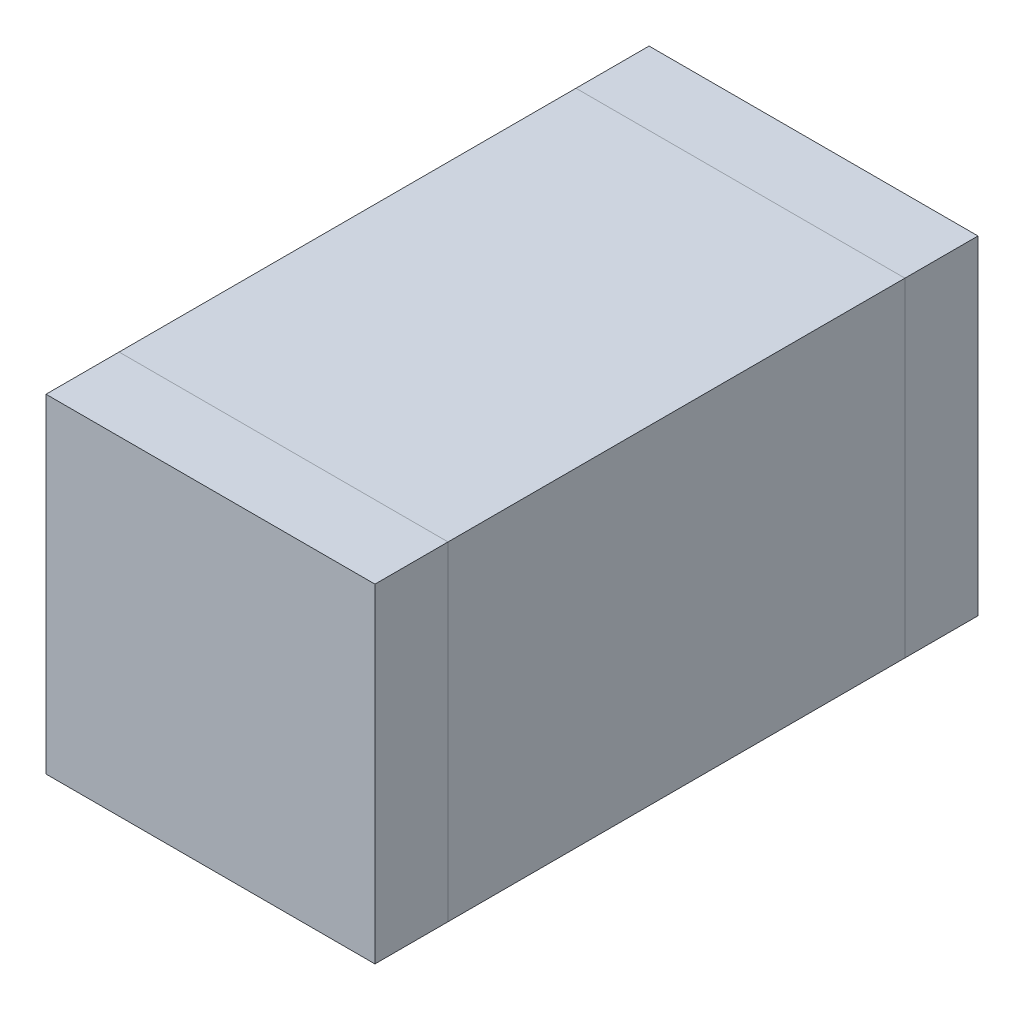
from build123d import *

# Parameters (mm, degrees)
SKETCH1_W  = 1.8
SKETCH1_H  = 2.5
MB_DEPTH   = 1.8
SKETCH2_W  = 1.8
SKETCH2_H  = 1.8
SB_L_DEPTH = 0.4
SKETCH3_W  = 1.8
SKETCH3_H  = 1.8
SB_R_DEPTH = 0.4


with BuildPart() as part:
    # Sketch1 → MB (new body)
    with BuildSketch(Plane(origin=(0, 0, 0), x_dir=(1, 0, 0), z_dir=(0, 1, 0))):
        Rectangle(SKETCH1_W, SKETCH1_H)
    extrude(amount=MB_DEPTH)


with BuildPart() as body_2:
    # Sketch2 → SB L (new body)
    with BuildSketch(Plane.XY.offset(1.25)):
        with Locations((0, 0.9)):
            Rectangle(SKETCH2_W, SKETCH2_H)
    extrude(amount=SB_L_DEPTH)


with BuildPart() as body_3:
    # Sketch3 → SB R (new body)
    with BuildSketch(Plane(origin=(0, 0, -1.25), x_dir=(-1, 0, 0), z_dir=(0, 0, -1))):
        with Locations((0, 0.9)):
            Rectangle(SKETCH3_W, SKETCH3_H)
    extrude(amount=SB_R_DEPTH)


solid = Compound([part.part, body_2.part, body_3.part])
